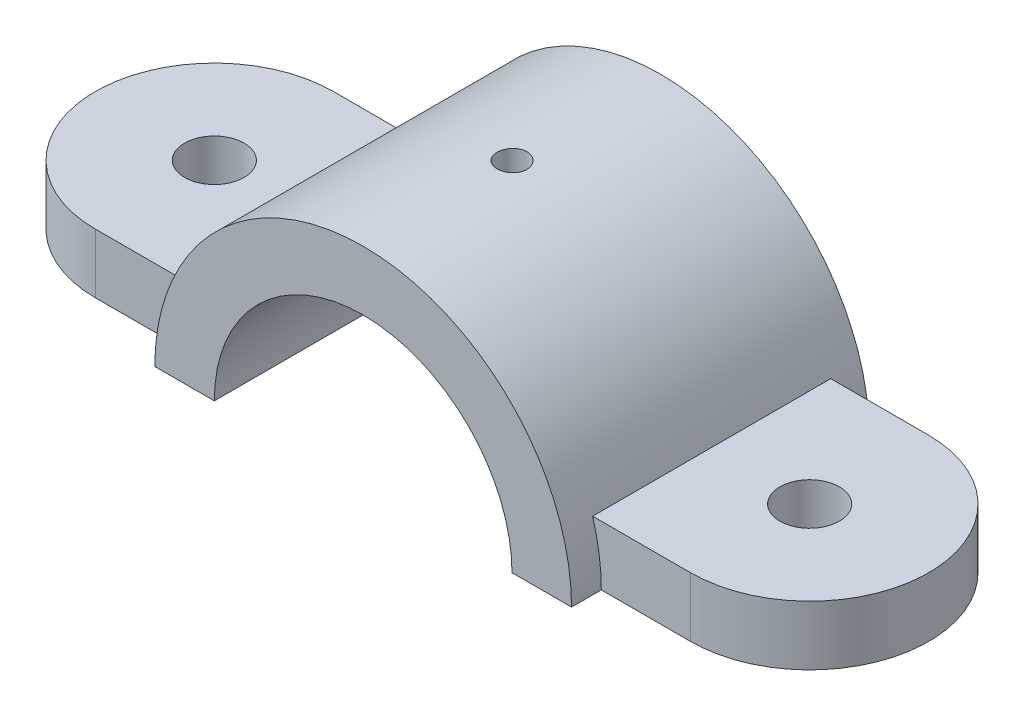
from build123d import *

# Parameters (mm, degrees)
SLOTSKETCH_R      = 6.35
SLOTEXTRUDE_DEPTH = 12.7
ARCEXTRUDE_DEPTH  = 31.75
CENTERDRILL_D     = 6.35
ARCPROFILE_DEPTH  = 64.5000001


with BuildPart() as part:
    # slotSketch → slotExtrude (new body)
    with BuildSketch(Plane(origin=(0, 0, 0), x_dir=(1, 0, 0), z_dir=(0, 1, 0))):
        with BuildLine():
            Line((-63.5, 25.4), (63.5, 25.4))
            ThreePointArc((63.5, 25.4), (88.9, 0), (63.5, -25.4))
            Line((63.5, -25.4), (-63.5, -25.4))
            ThreePointArc((-63.5, -25.4), (-88.9, 0), (-63.5, 25.4))
        make_face()
        with Locations((63.5, 0)):
            Circle(SLOTSKETCH_R, mode=Mode.SUBTRACT)
        with Locations((-63.5, 0)):
            Circle(SLOTSKETCH_R, mode=Mode.SUBTRACT)
    extrude(amount=SLOTEXTRUDE_DEPTH)

    # Sketch3 → arcExtrude (add, symmetric)
    with BuildSketch(Plane.XY):
        with BuildLine():
            Line((-44.45, 0), (44.45, 0))
            ThreePointArc((44.45, 0), (0, 44.45), (-44.45, 0))
        make_face()
    extrude(amount=ARCEXTRUDE_DEPTH, both=True)

    # centerDrill (through all)
    with Locations(Plane(origin=(0, 0, 0), x_dir=(-1, 0, 0), z_dir=(0, -1, 0))):
        with Locations((0, 0)):
            Hole(CENTERDRILL_D / 2)

    # Sketch7 → arcProfile (cut, through all)
    with BuildSketch(Plane.XY.offset(31.75)):
        with BuildLine():
            Line((-31.75, 0), (31.75, 0))
            ThreePointArc((31.75, 0), (0, 31.75), (-31.75, 0))
        make_face()
    extrude(amount=-ARCPROFILE_DEPTH, mode=Mode.SUBTRACT)


solid = part.part
